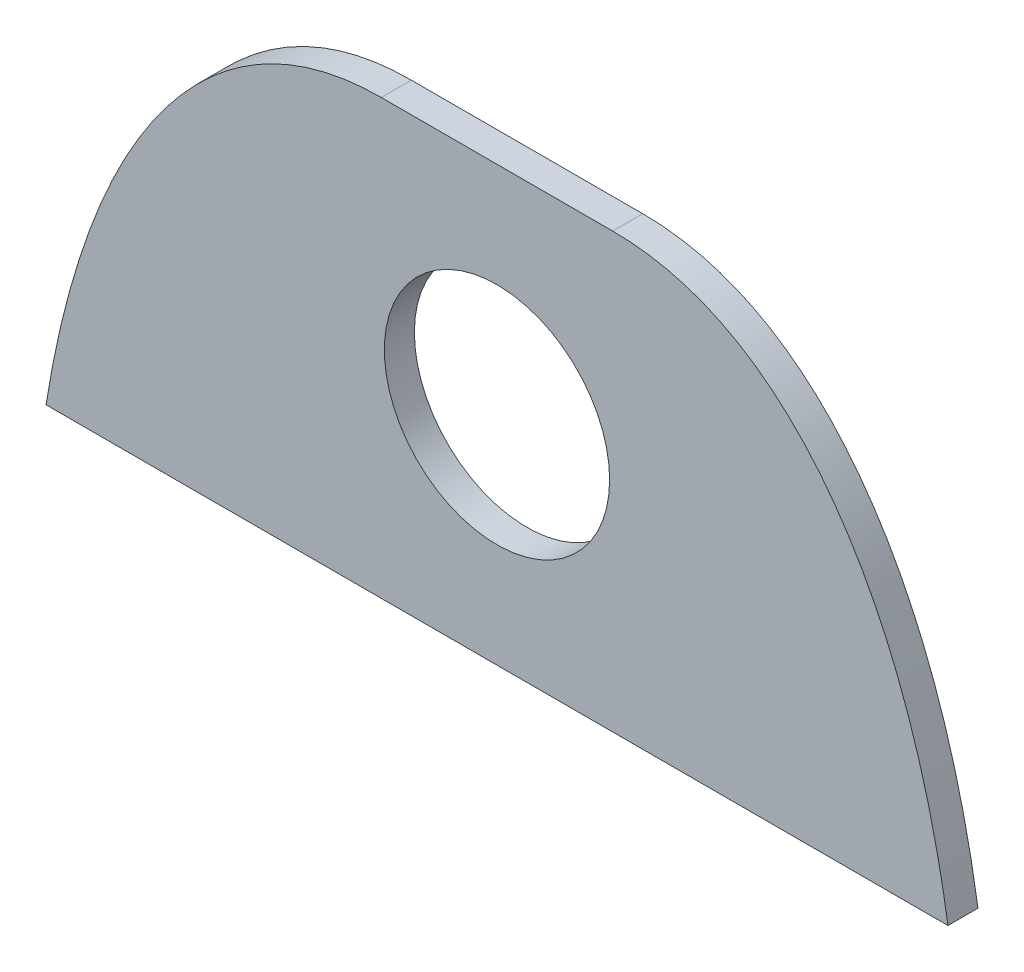
from build123d import *

# Parameters (mm, degrees)
BOSS_EXTRUDE1_DEPTH = 0.508
SKETCH3_R           = 1.905
CUT_EXTRUDE1_DEPTH  = 1.5080001


with BuildPart() as part:
    # Sketch1 → Boss-Extrude1 (new body)
    with BuildSketch(Plane.XY):
        with BuildLine():
            Line((0, 0), (15.252199682, 0))
            add(Edge.make_bspline(
                [(15.252199682, 0), (15.120704697, 0.830694341), (14.937497846, 1.646944845), (14.553106346, 2.840713056), (14.406511336, 3.233478401), (14.065397829, 4.0056234), (13.872436019, 4.381220548), (13.432237437, 5.09798559), (13.181982939, 5.443027105), (12.622569242, 6.068152419), (12.313627231, 6.349687516), (11.791041042, 6.709189105), (11.607426909, 6.817668629), (11.230562195, 7.003786767), (11.035975482, 7.082401547), (10.633831708, 7.209189667), (10.425174386, 7.257312019), (10.006679556, 7.320082622), (9.795580815, 7.335304029), (9.582738696, 7.335304029)],
                knots=[0, 0, 0, 0, 0.25, 0.25, 0.375, 0.375, 0.5, 0.5, 0.625, 0.625, 0.75, 0.75, 0.8125, 0.8125, 0.875, 0.875, 0.9375, 0.9375, 1, 1, 1, 1], degree=3))
            Line((9.582738696, 7.335304029), (5.669460986, 7.335304029))
            add(Edge.make_bspline(
                [(5.669460986, 7.335304029), (5.243996086, 7.335304029), (4.828702614, 7.274669933), (4.222365546, 7.084743854), (4.024617237, 7.005080674), (3.647485659, 6.819183421), (3.466491387, 6.712483598), (3.118434336, 6.473781927), (2.950963248, 6.341174992), (2.637156438, 6.060474457), (2.489557897, 5.911629159), (2.070541236, 5.44338386), (1.820997709, 5.099528272), (1.159883637, 4.023480986), (0.833207908, 3.254615604), (0.445697358, 2.055038054), (0.334748926, 1.647706186), (0.144996604, 0.828712342), (0.06582017, 0.415806296), (0, 0)],
                knots=[0, 0, 0, 0, 0.125, 0.125, 0.1875, 0.1875, 0.25, 0.25, 0.3125, 0.3125, 0.375, 0.375, 0.5, 0.5, 0.75, 0.75, 0.875, 0.875, 1, 1, 1, 1], degree=3))
        make_face()
    extrude(amount=BOSS_EXTRUDE1_DEPTH)

    # Sketch3 → Cut-Extrude1 (cut, through all)
    with BuildSketch(Plane.XY.offset(0.508)):
        with Locations((7.626099841, 3.667652015)):
            Circle(SKETCH3_R)
    extrude(amount=-CUT_EXTRUDE1_DEPTH, mode=Mode.SUBTRACT)


solid = part.part
